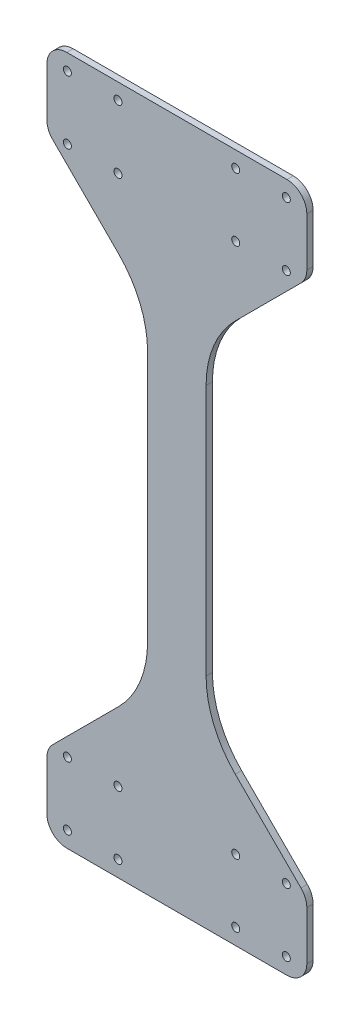
from build123d import *

# Parameters (mm, degrees)
BOSS_EXTRUDE1_DEPTH = 3.175
CUT_EXTRUDE1_DEPTH  = 10
SKETCH3_R           = 2.0193
BOSS_EXTRUDE2_DEPTH = 3.175
FILLET1_R           = 10
FILLET2_R           = 50
SKETCH4_R           = 2.02
CUT_EXTRUDE2_DEPTH  = 10


with BuildPart() as part:
    # Sketch1 → Boss-Extrude1 (new body)
    with BuildSketch(Plane.XY):
        Polygon((165.934536959, -16.66935), (157.315236959, -8.05005), (115.359952094, -8.05005), (89.959952094, -8.05005), (48.004667228, -8.05005), (39.385367228, -16.66935), (39.385367228, -40.05005), (39.385367228, -52.41105), (165.934536959, -56.67505), (165.934536959, -42.05005), align=None)
        with BuildLine():
            ThreePointArc((47.685367228, -44.38075), (49.704667228, -46.40005), (47.685367228, -48.41935))
            ThreePointArc((47.685367228, -48.41935), (45.666067228, -46.40005), (47.685367228, -44.38075))
        make_face(mode=Mode.SUBTRACT)
        with BuildLine():
            ThreePointArc((47.685367228, -12.63075), (49.704667228, -14.65005), (47.685367228, -16.66935))
            ThreePointArc((47.685367228, -16.66935), (45.666067228, -14.65005), (47.685367228, -12.63075))
        make_face(mode=Mode.SUBTRACT)
        with BuildLine():
            ThreePointArc((73.085367228, -44.38075), (75.104667228, -46.40005), (73.085367228, -48.41935))
            ThreePointArc((73.085367228, -48.41935), (71.066067228, -46.40005), (73.085367228, -44.38075))
        make_face(mode=Mode.SUBTRACT)
        with BuildLine():
            ThreePointArc((73.085367228, -12.63075), (75.104667228, -14.65005), (73.085367228, -16.66935))
            ThreePointArc((73.085367228, -16.66935), (71.066067228, -14.65005), (73.085367228, -12.63075))
        make_face(mode=Mode.SUBTRACT)
        with BuildLine():
            ThreePointArc((132.234536959, -44.38075), (134.253836959, -46.40005), (132.234536959, -48.41935))
            ThreePointArc((132.234536959, -48.41935), (130.215236959, -46.40005), (132.234536959, -44.38075))
        make_face(mode=Mode.SUBTRACT)
        with BuildLine():
            ThreePointArc((132.234536959, -12.63075), (134.253836959, -14.65005), (132.234536959, -16.66935))
            ThreePointArc((132.234536959, -16.66935), (130.215236959, -14.65005), (132.234536959, -12.63075))
        make_face(mode=Mode.SUBTRACT)
        with BuildLine():
            ThreePointArc((157.634536959, -44.38075), (159.653836959, -46.40005), (157.634536959, -48.41935))
            ThreePointArc((157.634536959, -48.41935), (155.615236959, -46.40005), (157.634536959, -44.38075))
        make_face(mode=Mode.SUBTRACT)
        with BuildLine():
            ThreePointArc((157.634536959, -12.63075), (159.653836959, -14.65005), (157.634536959, -16.66935))
            ThreePointArc((157.634536959, -16.66935), (155.615236959, -14.65005), (157.634536959, -12.63075))
        make_face(mode=Mode.SUBTRACT)
        Polygon((115.359952094, -8.05005), (157.315236959, -8.05005), (115.359952094, 33.905234866), align=None)
        Polygon((89.959952094, -8.05005), (115.359952094, -8.05005), (115.359952094, 33.905234866), (115.359952094, 203.394265134), (115.359952094, 245.34955), (89.959952094, 245.34955), (89.959952094, 203.394265134), (89.959952094, 33.905234866), align=None)
        Polygon((48.004667228, -8.05005), (89.959952094, -8.05005), (89.959952094, 33.905234866), align=None)
        Polygon((89.959952094, 245.34955), (115.359952094, 245.34955), (157.315236959, 245.34955), (165.934536959, 253.96885), (165.934536959, 279.34955), (165.934536959, 293.97455), (39.385367228, 289.71055), (39.385367228, 277.34955), (39.385367228, 253.96885), (48.004667228, 245.34955), align=None)
        with BuildLine():
            ThreePointArc((47.685367228, 253.96885), (49.704667228, 251.94955), (47.685367228, 249.93025))
            ThreePointArc((47.685367228, 249.93025), (45.666067228, 251.94955), (47.685367228, 253.96885))
        make_face(mode=Mode.SUBTRACT)
        with BuildLine():
            ThreePointArc((47.685367228, 285.71885), (49.704667228, 283.69955), (47.685367228, 281.68025))
            ThreePointArc((47.685367228, 281.68025), (45.666067228, 283.69955), (47.685367228, 285.71885))
        make_face(mode=Mode.SUBTRACT)
        with BuildLine():
            ThreePointArc((73.085367228, 253.96885), (75.104667228, 251.94955), (73.085367228, 249.93025))
            ThreePointArc((73.085367228, 249.93025), (71.066067228, 251.94955), (73.085367228, 253.96885))
        make_face(mode=Mode.SUBTRACT)
        with BuildLine():
            ThreePointArc((73.085367228, 285.71885), (75.104667228, 283.69955), (73.085367228, 281.68025))
            ThreePointArc((73.085367228, 281.68025), (71.066067228, 283.69955), (73.085367228, 285.71885))
        make_face(mode=Mode.SUBTRACT)
        with BuildLine():
            ThreePointArc((132.234536959, 253.96885), (134.253836959, 251.94955), (132.234536959, 249.93025))
            ThreePointArc((132.234536959, 249.93025), (130.215236959, 251.94955), (132.234536959, 253.96885))
        make_face(mode=Mode.SUBTRACT)
        with BuildLine():
            ThreePointArc((157.634536959, 253.96885), (159.653836959, 251.94955), (157.634536959, 249.93025))
            ThreePointArc((157.634536959, 249.93025), (155.615236959, 251.94955), (157.634536959, 253.96885))
        make_face(mode=Mode.SUBTRACT)
        with BuildLine():
            ThreePointArc((157.634536959, 285.71885), (159.653836959, 283.69955), (157.634536959, 281.68025))
            ThreePointArc((157.634536959, 281.68025), (155.615236959, 283.69955), (157.634536959, 285.71885))
        make_face(mode=Mode.SUBTRACT)
        Polygon((115.359952094, 245.34955), (115.359952094, 203.394265134), (157.315236959, 245.34955), align=None)
        Polygon((48.004667228, 245.34955), (89.959952094, 203.394265134), (89.959952094, 245.34955), align=None)
    extrude(amount=BOSS_EXTRUDE1_DEPTH)

    # Sketch2 → Cut-Extrude1 (cut)
    with BuildSketch(Plane.XY.offset(3.175)):
        Polygon((84.385367228, -52.41105), (39.385367228, -52.41105), (165.934536959, -56.67505), (165.934536959, -52.41105), (120.934536959, -52.41105), align=None)
        Polygon((120.934536959, 289.71055), (165.934536959, 289.71055), (165.934536959, 293.97455), (39.385367228, 289.71055), (84.385367228, 289.71055), align=None)
    extrude(amount=-CUT_EXTRUDE1_DEPTH, mode=Mode.SUBTRACT)

    # Sketch3 → Boss-Extrude2 (add)
    with BuildSketch(Plane.XY.offset(3.175)):
        Polygon((37.385367228, -15.840922875), (37.385367228, -54.41105), (167.934536959, -54.41105), (167.934536959, -15.840922875), (117.359952094, 34.73366199), (117.359952094, 202.56583801), (167.934536959, 253.140422875), (167.934536959, 291.71055), (37.385367228, 291.71055), (37.385367228, 253.140422875), (87.959952094, 202.56583801), (87.959952094, 34.73366199), align=None)
        with Locations((132.234536959, -46.40005)):
            Circle(SKETCH3_R, mode=Mode.SUBTRACT)
        with Locations((132.234536959, -14.65005)):
            Circle(SKETCH3_R, mode=Mode.SUBTRACT)
        with Locations((47.685367228, -14.65005)):
            Circle(SKETCH3_R, mode=Mode.SUBTRACT)
        with Locations((47.685367228, -46.40005)):
            Circle(SKETCH3_R, mode=Mode.SUBTRACT)
        with Locations((73.085367228, -46.40005)):
            Circle(SKETCH3_R, mode=Mode.SUBTRACT)
        with Locations((73.085367228, -14.65005)):
            Circle(SKETCH3_R, mode=Mode.SUBTRACT)
        with Locations((157.634536959, -14.65005)):
            Circle(SKETCH3_R, mode=Mode.SUBTRACT)
        with Locations((157.634536959, -46.40005)):
            Circle(SKETCH3_R, mode=Mode.SUBTRACT)
        with Locations((132.234536959, 251.94955)):
            Circle(SKETCH3_R, mode=Mode.SUBTRACT)
        with Locations((73.085367228, 251.94955)):
            Circle(SKETCH3_R, mode=Mode.SUBTRACT)
        with Locations((157.634536959, 251.94955)):
            Circle(SKETCH3_R, mode=Mode.SUBTRACT)
        with Locations((47.685367228, 251.94955)):
            Circle(SKETCH3_R, mode=Mode.SUBTRACT)
        with Locations((47.685367228, 283.69955)):
            Circle(SKETCH3_R, mode=Mode.SUBTRACT)
        with Locations((73.085367228, 283.69955)):
            Circle(SKETCH3_R, mode=Mode.SUBTRACT)
        with Locations((157.634536959, 283.69955)):
            Circle(SKETCH3_R, mode=Mode.SUBTRACT)
    extrude(amount=-BOSS_EXTRUDE2_DEPTH)

    # Fillet1
    fillet1_edges = [part.edges().sort_by_distance(p)[0] for p in [
        (37.385367228, -54.41105, 1.5875),
        (167.934536959, -54.41105, 1.5875),
        (167.934536959, -15.840922875, 1.5875),
        (167.934536959, 253.140422875, 1.5875),
        (167.934536959, 291.71055, 1.5875),
        (37.385367228, 291.71055, 1.5875),
        (37.385367228, 253.140422875, 1.5875),
        (37.385367228, -15.840922875, 1.5875),
    ]]
    fillet(fillet1_edges, radius=FILLET1_R)

    # Fillet2
    fillet2_edges = [part.edges().sort_by_distance(p)[0] for p in [
        (117.359952094, 34.73366199, 1.5875),
        (117.359952094, 202.56583801, 1.5875),
        (87.959952094, 202.56583801, 1.5875),
        (87.959952094, 34.73366199, 1.5875),
    ]]
    fillet(fillet2_edges, radius=FILLET2_R)

    # Sketch4 → Cut-Extrude2 (cut)
    with BuildSketch(Plane.XY.offset(3.175)):
        with Locations((132.234536959, 283.69955)):
            Circle(SKETCH4_R)
    extrude(amount=-CUT_EXTRUDE2_DEPTH, mode=Mode.SUBTRACT)


solid = part.part
